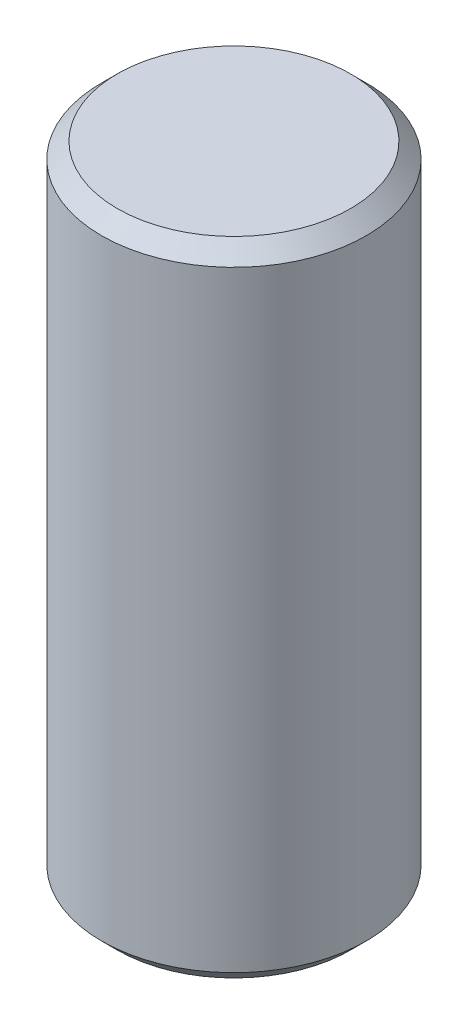
from build123d import *

# Parameters (mm, degrees)
SKETCH1_R           = 429.26
BOSS_EXTRUDE1_DEPTH = 2082.8
CHAMFER2_SIZE       = 50.8


with BuildPart() as part:
    # Sketch1 → Boss-Extrude1 (new body)
    with BuildSketch(Plane(origin=(0, 0, 0), x_dir=(1, 0, 0), z_dir=(0, 1, 0))):
        Circle(SKETCH1_R)
    extrude(amount=BOSS_EXTRUDE1_DEPTH)

    # Chamfer2
    chamfer2_edges = [part.edges().sort_by_distance(p)[0] for p in [
        (-429.26, 0, 0),
        (-429.26, 2082.8, 0),
    ]]
    chamfer(chamfer2_edges, length=CHAMFER2_SIZE)


solid = part.part
